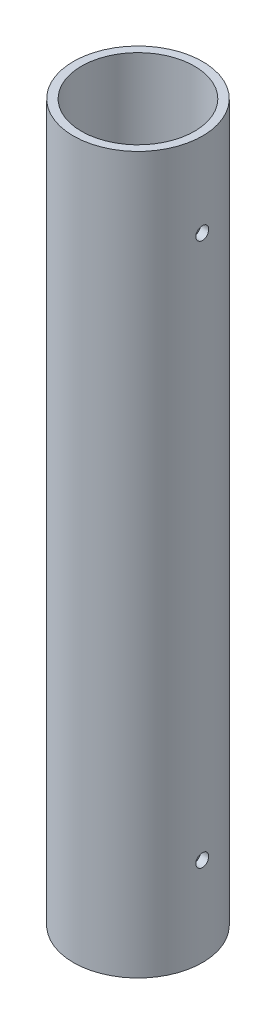
from build123d import *

# Parameters (mm, degrees)
SKETCH2_R           = 8
SKETCH2_R_2         = 7
BOSS_EXTRUDE2_DEPTH = 88.69527324
M2_TAPPED_HOLE1_D   = 1.6
M2_TAPPED_HOLE2_D   = 1.6


with BuildPart() as part:
    # Sketch2 → Boss-Extrude2 (new body)
    with BuildSketch(Plane(origin=(0, 0, 0), x_dir=(1, 0, 0), z_dir=(0, 1, 0))):
        Circle(SKETCH2_R)
        Circle(SKETCH2_R_2, mode=Mode.SUBTRACT)
    extrude(amount=BOSS_EXTRUDE2_DEPTH)

    # M2 Tapped Hole1 (through all)
    with Locations(Plane(origin=(8, 0, 0), x_dir=(0, 0, -1), z_dir=(1, 0, 0))):
        with Locations((0, 78.27915224)):
            Hole(M2_TAPPED_HOLE1_D / 2)

    # M2 Tapped Hole2 (through all)
    with Locations(Plane(origin=(8, 0, 0), x_dir=(0, 0, -1), z_dir=(1, 0, 0))):
        with Locations((0, 11)):
            Hole(M2_TAPPED_HOLE2_D / 2)


solid = part.part
